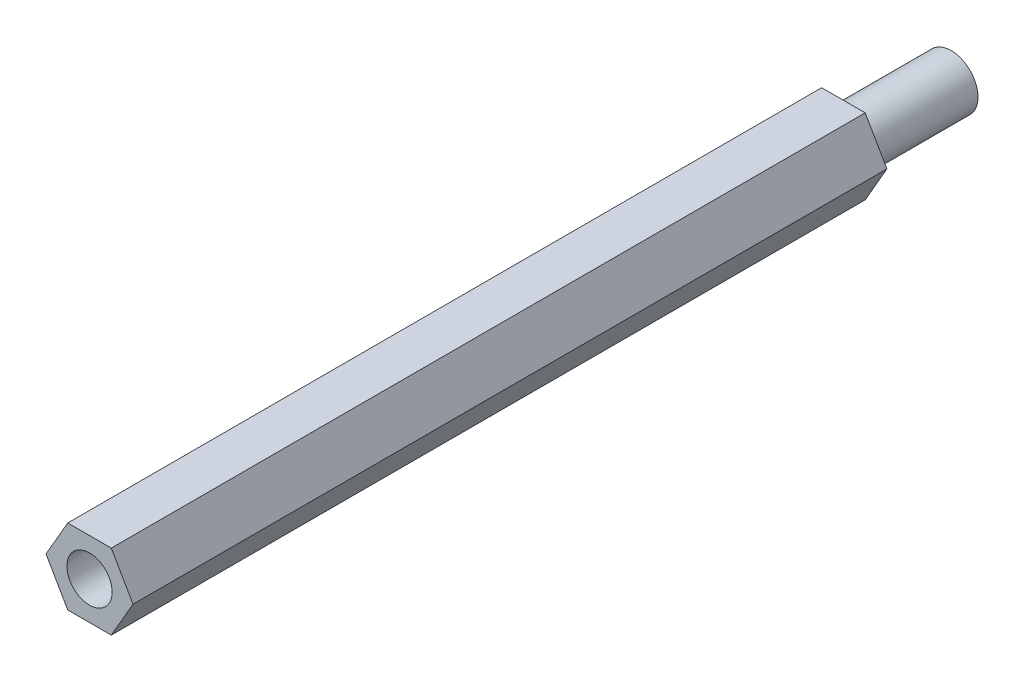
from build123d import *

# Parameters (mm, degrees)
EXTRUDE_1_DEPTH           = 70
SKETCH_4_R                = 2.5
EXTRUDE_2_DEPTH           = 10
M5X0_8_TAPPED_HOLE1_D     = 4.2
M5X0_8_TAPPED_HOLE1_DEPTH = 12.4
M5X0_8_TAPPED_HOLE1_TIP   = 1.2618073


with BuildPart() as part:
    # 草圖1 → 填料-伸長1 (new body)
    with BuildSketch(Plane.XY):
        Polygon((-2.020725942, 3.5), (-4.041451884, 0), (-2.020725942, -3.5), (2.020725942, -3.5), (4.041451884, 0), (2.020725942, 3.5), align=None)
    extrude(amount=EXTRUDE_1_DEPTH)

    # 草圖4 → 填料-伸長2 (add)
    with BuildSketch(Plane(origin=(0, 0, 0), x_dir=(-1, 0, 0), z_dir=(0, 0, -1))):
        Circle(SKETCH_4_R)
    extrude(amount=EXTRUDE_2_DEPTH)

    # M5x0.8 Tapped Hole1
    with Locations(Plane.XY.offset(70)):
        with Locations((0, 0)):
            Hole(M5X0_8_TAPPED_HOLE1_D / 2, depth=M5X0_8_TAPPED_HOLE1_DEPTH)
            with Locations((0, 0, -(M5X0_8_TAPPED_HOLE1_DEPTH + M5X0_8_TAPPED_HOLE1_TIP / 2))):  # 118° drill point
                Cone(0, M5X0_8_TAPPED_HOLE1_D / 2, M5X0_8_TAPPED_HOLE1_TIP, mode=Mode.SUBTRACT)


solid = part.part
